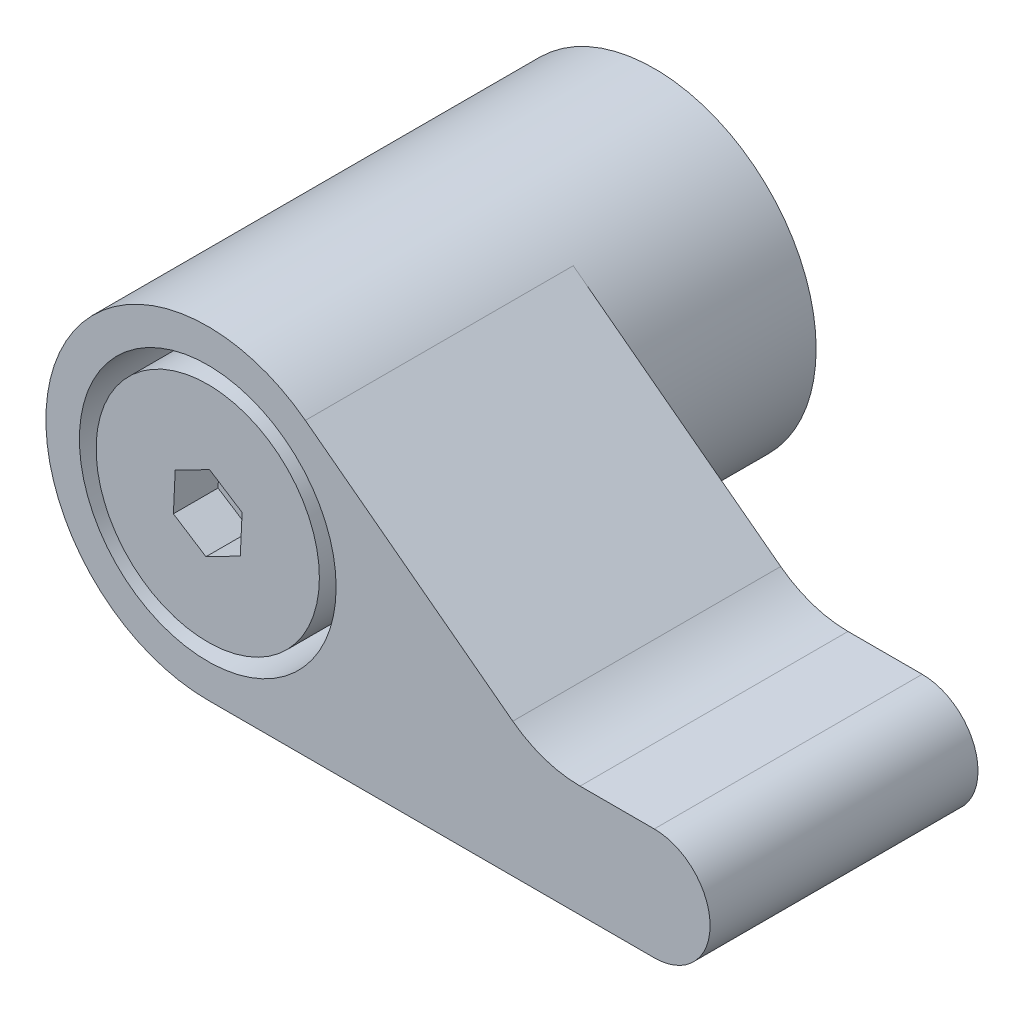
from build123d import *

# Parameters (mm, degrees)
SKETCH_1_R          = 7.25
EXTRUDE_1_DEPTH     = 20
EXTRUDE_2_DEPTH     = 12
FILLET_1_R          = 5
SKETCH_3_R          = 5.75
CUT_EXTRUDE_1_DEPTH = 10
SKETCH_4_R          = 5
EXTRUDE_3_DEPTH     = 10
CUT_EXTRUDE_2_DEPTH = 2


with BuildPart() as part:
    # Эскиз1 → Бобышка-Вытянуть1 (new body)
    with BuildSketch(Plane.XY):
        Circle(SKETCH_1_R)
    extrude(amount=EXTRUDE_1_DEPTH)

    # Эскиз2 → Бобышка-Вытянуть2 (add)
    with BuildSketch(Plane.XY.offset(20)):
        with BuildLine():
            Line((0, -7.25), (20, -7.25))
            ThreePointArc((20, -7.25), (22.5, -4.75), (20, -2.25))
            Line((20, -2.25), (15, -2.25))
            Line((15, -2.25), (4.371714259, 5.783650615))
            ThreePointArc((4.371714259, 5.783650615), (-6.873644119, 2.305540397), (0, -7.25))
        make_face()
    extrude(amount=-EXTRUDE_2_DEPTH)

    # Скругление1
    fillet_1_edges = [part.edges().sort_by_distance(p)[0] for p in [
        (15, -2.25, 14),
    ]]
    fillet(fillet_1_edges, radius=FILLET_1_R)

    # Эскиз3 → Вырез-Вытянуть1 (cut)
    with BuildSketch(Plane.XY.offset(20)):
        Circle(SKETCH_3_R)
    extrude(amount=-CUT_EXTRUDE_1_DEPTH, mode=Mode.SUBTRACT)

    # Эскиз4 → Бобышка-Вытянуть3 (add)
    with BuildSketch(Plane.XY.offset(10)):
        Circle(SKETCH_4_R)
    extrude(amount=EXTRUDE_3_DEPTH)

    # Эскиз5 → Вырез-Вытянуть2 (cut)
    with BuildSketch(Plane.XY.offset(20)):
        Polygon((1.457985788, -0.935028044), (1.538750933, 0.795138708), (0.080765145, 1.730166752), (-1.457985788, 0.935028044), (-1.538750933, -0.795138708), (-0.080765145, -1.730166752), align=None)
    extrude(amount=-CUT_EXTRUDE_2_DEPTH, mode=Mode.SUBTRACT)


solid = part.part
